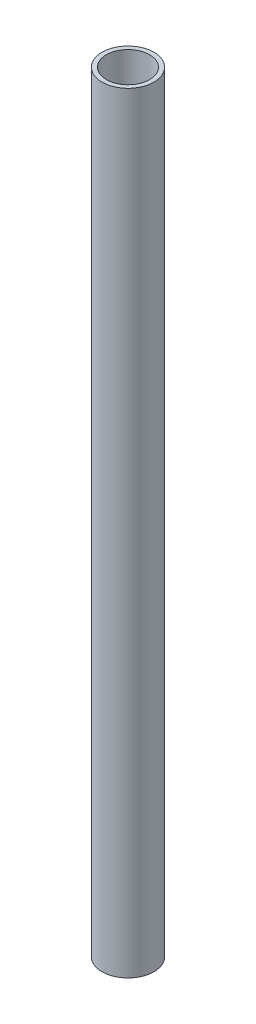
from build123d import *

# Parameters (mm, degrees)
SKETCH_1_R      = 3
SKETCH_1_R_2    = 2.5
EXTRUDE_1_DEPTH = 89.19


with BuildPart() as part:
    # 草图1 → 凸台-拉伸1 (new body)
    with BuildSketch(Plane(origin=(0, 0, 0), x_dir=(1, 0, 0), z_dir=(0, 1, 0))):
        Circle(SKETCH_1_R)
        Circle(SKETCH_1_R_2, mode=Mode.SUBTRACT)
    extrude(amount=EXTRUDE_1_DEPTH)


solid = part.part
